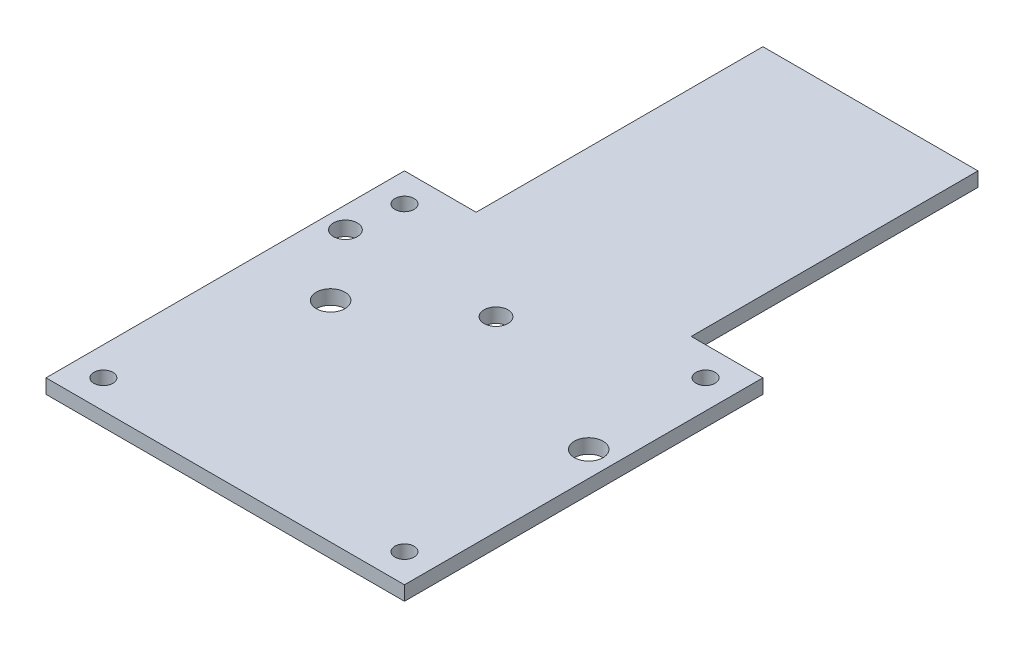
from build123d import *

# Parameters (mm, degrees)
SKETCH1_R           = 2
SKETCH1_R_2         = 3
SKETCH1_R_3         = 2.5
BOSS_EXTRUDE1_DEPTH = 3


with BuildPart() as part:
    # Sketch1 → Boss-Extrude1 (new body)
    with BuildSketch(Plane(origin=(0, 0, 0), x_dir=(1, 0, 0), z_dir=(0, 1, 0))):
        Polygon((22.5, 37.5), (37.5, 37.5), (37.5, -37.5), (-37.5, -37.5), (-37.5, 37.5), (-22.5, 37.5), (-22.5, 97.5), (22.5, 97.5), align=None)
        with Locations((31.5, 31.5)):
            Circle(SKETCH1_R, mode=Mode.SUBTRACT)
        with Locations((31.5, -31.5)):
            Circle(SKETCH1_R, mode=Mode.SUBTRACT)
        with Locations((-31.5, -31.5)):
            Circle(SKETCH1_R, mode=Mode.SUBTRACT)
        with Locations((-31.5, 31.5)):
            Circle(SKETCH1_R, mode=Mode.SUBTRACT)
        with Locations((32.25, 6.3)):
            Circle(SKETCH1_R_2, mode=Mode.SUBTRACT)
        with Locations((-21.75, 6.3)):
            Circle(SKETCH1_R_2, mode=Mode.SUBTRACT)
        with Locations((-33, 20.65)):
            Circle(SKETCH1_R_3, mode=Mode.SUBTRACT)
        with Locations((-1.5, 20.65)):
            Circle(SKETCH1_R_3, mode=Mode.SUBTRACT)
    extrude(amount=BOSS_EXTRUDE1_DEPTH)


solid = part.part
